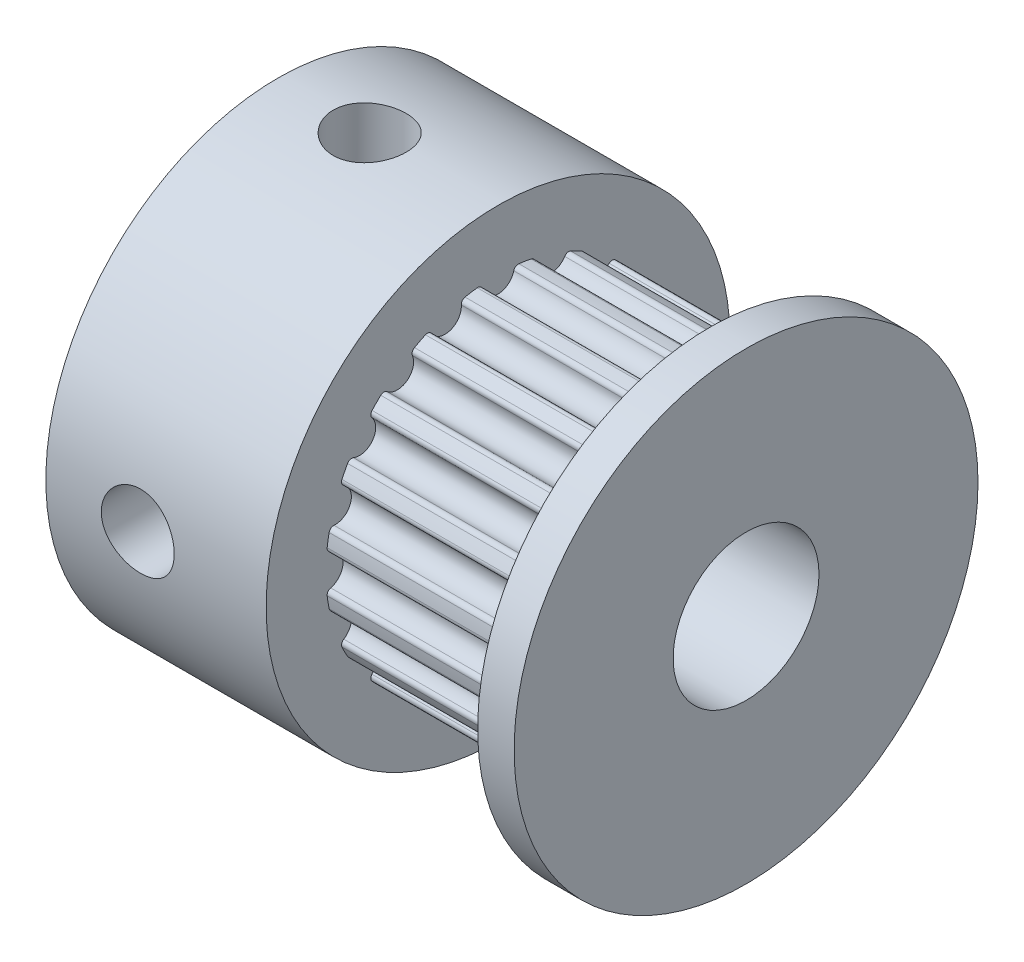
from build123d import *

# Parameters (mm, degrees)
CROQUIS5_R            = 0.555
CORTAR_EXTRUIR1_DEPTH = 7.25
REDONDEO1_R           = 0.16
SKETCH2_W             = 1.25
SKETCH2_H             = 7.95
SKETCH4_W             = 1.25
SKETCH4_H             = 7.95


with BuildPart() as part:
    # Sketch1 → Revolve1 (revolve)
    with BuildSketch(Plane.XY):
        Polygon((0, 7.95), (7.55, 7.95), (7.55, 5.9), (14.8, 5.9), (14.8, 7.95), (16.05, 7.95), (16.05, 2.5), (0, 2.5), align=None)
    revolve(axis=Axis((0, 0, 0), (-1, 0, 0)))

    # Croquis5 → Cortar-Extruir1 (cut)
    with BuildSketch(Plane.ZY.offset(-14.8)):
        with Locations((0, 5.87)):
            Circle(CROQUIS5_R)
        with Locations((1.813929757, 5.582701751)):
            Circle(CROQUIS5_R)
        with Locations((3.450299431, 4.748929757)):
            Circle(CROQUIS5_R)
        with Locations((4.748929757, 3.450299431)):
            Circle(CROQUIS5_R)
        with Locations((5.582701751, 1.813929757)):
            Circle(CROQUIS5_R)
        with Locations((5.87, 0)):
            Circle(CROQUIS5_R)
        with Locations((5.582701751, -1.813929757)):
            Circle(CROQUIS5_R)
        with Locations((4.748929757, -3.450299431)):
            Circle(CROQUIS5_R)
        with Locations((3.450299431, -4.748929757)):
            Circle(CROQUIS5_R)
        with Locations((1.813929757, -5.582701751)):
            Circle(CROQUIS5_R)
        with Locations((0, -5.87)):
            Circle(CROQUIS5_R)
        with Locations((-1.813929757, -5.582701751)):
            Circle(CROQUIS5_R)
        with Locations((-3.450299431, -4.748929757)):
            Circle(CROQUIS5_R)
        with Locations((-4.748929757, -3.450299431)):
            Circle(CROQUIS5_R)
        with Locations((-5.582701751, -1.813929757)):
            Circle(CROQUIS5_R)
        with Locations((-5.87, 0)):
            Circle(CROQUIS5_R)
        with Locations((-5.582701751, 1.813929757)):
            Circle(CROQUIS5_R)
        with Locations((-4.748929757, 3.450299431)):
            Circle(CROQUIS5_R)
        with Locations((-3.450299431, 4.748929757)):
            Circle(CROQUIS5_R)
        with Locations((-1.813929757, 5.582701751)):
            Circle(CROQUIS5_R)
    extrude(amount=CORTAR_EXTRUIR1_DEPTH, mode=Mode.SUBTRACT)

    # Redondeo1
    redondeo1_edges = [part.edges().sort_by_distance(p)[0] for p in [
        (11.175, -5.757853601, 1.287292473),
        (11.175, -5.414852945, 2.342939944),
        (11.175, -5.873839438, -0.554986719),
        (11.175, -5.873839438, 0.554986719),
        (11.175, -5.414852945, -2.342939944),
        (11.175, -5.757853601, -1.287292473),
        (11.175, -4.425822919, -3.901549884),
        (11.175, -5.078248936, -3.003562508),
        (11.175, -3.003562508, -5.078248936),
        (11.175, -3.901549884, -4.425822919),
        (11.175, -1.287292473, -5.757853601),
        (11.175, -2.342939944, -5.414852945),
        (11.175, 0.554986719, -5.873839438),
        (11.175, -0.554986719, -5.873839438),
        (11.175, 2.342939944, -5.414852945),
        (11.175, 1.287292473, -5.757853601),
        (11.175, 3.901549884, -4.425822919),
        (11.175, 3.003562508, -5.078248936),
        (11.175, 5.078248936, -3.003562508),
        (11.175, 4.425822919, -3.901549884),
        (11.175, 5.757853601, -1.287292473),
        (11.175, 5.414852945, -2.342939944),
        (11.175, 5.873839438, 0.554986719),
        (11.175, 5.873839438, -0.554986719),
        (11.175, 5.414852945, 2.342939944),
        (11.175, 5.757853601, 1.287292473),
        (11.175, 4.425822919, 3.901549884),
        (11.175, 5.078248936, 3.003562508),
        (11.175, 3.003562508, 5.078248936),
        (11.175, 3.901549884, 4.425822919),
        (11.175, 1.287292473, 5.757853601),
        (11.175, 2.342939944, 5.414852945),
        (11.175, -0.554986719, 5.873839438),
        (11.175, 0.554986719, 5.873839438),
        (11.175, -2.342939944, 5.414852945),
        (11.175, -1.287292473, 5.757853601),
        (11.175, -3.901549884, 4.425822919),
        (11.175, -3.003562508, 5.078248936),
        (11.175, -5.078248936, 3.003562508),
        (11.175, -4.425822919, 3.901549884),
    ]]
    fillet(redondeo1_edges, radius=REDONDEO1_R)

    # Sketch2 → M3x0.5 Tapped Hole1 (revolve, cut)
    with BuildSketch(Plane(origin=(3.15, 0, 0), x_dir=(0, 0, -1), z_dir=(1, 0, 0))):
        with Locations((0.625, 3.975)):
            Rectangle(SKETCH2_W, SKETCH2_H)
    revolve(axis=Axis((3.15, -6.35, 0), (0, 1, 0)), mode=Mode.SUBTRACT)

    # Sketch4 → M3x0.5 Tapped Hole2 (revolve, cut)
    with BuildSketch(Plane.YZ.offset(3.15)):
        with Locations((0.625, 3.975)):
            Rectangle(SKETCH4_W, SKETCH4_H)
    revolve(axis=Axis((3.15, 0, -6.35), (0, 0, 1)), mode=Mode.SUBTRACT)


solid = part.part
